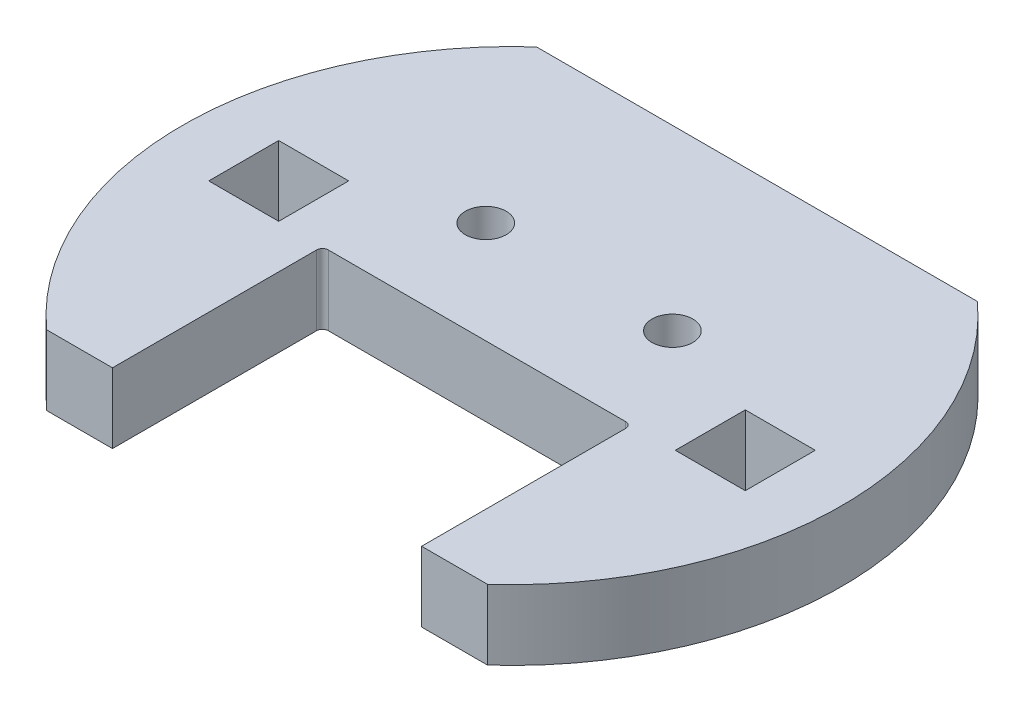
from build123d import *

# Parameters (mm, degrees)
SALIENTE_EXTRUIR1_DEPTH = 6
CROQUIS7_R              = 40
SALIENTE_EXTRUIR5_DEPTH = 6
SALIENTE_EXTRUIR3_DEPTH = 6
CROQUIS6_R              = 1.75
SALIENTE_EXTRUIR4_DEPTH = 6
CROQUIS8_W              = 6
CROQUIS8_H              = 6
CORTAR_EXTRUIR1_DEPTH   = 25
CROQUIS9_W              = 322
CROQUIS9_H              = 247
CORTAR_EXTRUIR2_DEPTH   = 12
CROQUIS10_R             = 28.25
CORTAR_EXTRUIR3_DEPTH   = 6


with BuildPart() as part:
    # Croquis1 → Saliente-Extruir1 (new body)
    with BuildSketch(Plane(origin=(0, 0, 0), x_dir=(1, 0, 0), z_dir=(0, 1, 0))):
        with BuildLine():
            Line((-161, 103.5), (-38.791887254, 9.756509788))
            ThreePointArc((-38.791887254, 9.756509788), (-40, 0), (-38.791887254, -9.756509788))
            Line((-38.791887254, -9.756509788), (-161, -103.5))
            Line((-161, -103.5), (-161, -123.5))
            Line((-161, -123.5), (-141, -123.5))
            Line((-141, -123.5), (-22.823766962, -32.84928708))
            ThreePointArc((-22.823766962, -32.84928708), (0, -40), (22.823766962, -32.84928708))
            Line((22.823766962, -32.84928708), (141, -123.5))
            Line((141, -123.5), (161, -123.5))
            Line((161, -123.5), (161, -103.5))
            Line((161, -103.5), (38.791887254, -9.756509788))
            ThreePointArc((38.791887254, -9.756509788), (40, 0), (38.791887254, 9.756509788))
            Line((38.791887254, 9.756509788), (161, 103.5))
            Line((161, 103.5), (161, 123.5))
            Line((161, 123.5), (141, 123.5))
            Line((141, 123.5), (22.823766962, 32.84928708))
            ThreePointArc((22.823766962, 32.84928708), (0, 40), (-22.823766962, 32.84928708))
            Line((-22.823766962, 32.84928708), (-141, 123.5))
            Line((-141, 123.5), (-161, 123.5))
            Line((-161, 123.5), (-161, 103.5))
        make_face()
    extrude(amount=SALIENTE_EXTRUIR1_DEPTH)

    # Croquis7 → Saliente-Extruir5 (add)
    with BuildSketch(Plane(origin=(0, 0, 0), x_dir=(-1, 0, 0), z_dir=(0, -1, 0))):
        Circle(CROQUIS7_R)
    extrude(amount=SALIENTE_EXTRUIR5_DEPTH)

    # Croquis5 → Saliente-Extruir3 (add)
    with BuildSketch(Plane.XZ.offset(6)):
        with BuildLine():
            Line((18.896097481, -21), (-18.896097481, -21))
            ThreePointArc((-18.896097481, -21), (-28.25, 0), (-18.896097481, 21))
            Line((-18.896097481, 21), (-13.25, 21))
            Line((-13.25, 21), (-13.25, -11))
            Line((-13.25, -11), (13.25, -11))
            Line((13.25, -11), (13.25, 21))
            Line((13.25, 21), (18.896097481, 21))
            ThreePointArc((18.896097481, 21), (28.25, 0), (18.896097481, -21))
        make_face()
    extrude(amount=SALIENTE_EXTRUIR3_DEPTH)

    # Croquis6 → Saliente-Extruir4 (add)
    with BuildSketch(Plane.XZ.offset(12)):
        with BuildLine():
            Line((-18.896097481, 21), (-13.25, 21))
            Line((-13.25, 21), (-13.25, 3.5))
            ThreePointArc((-13.25, 3.5), (-13.103553391, 3.146446609), (-12.75, 3))
            Line((-12.75, 3), (12.75, 3))
            ThreePointArc((12.75, 3), (13.103553391, 3.146446609), (13.25, 3.5))
            Line((13.25, 3.5), (13.25, 21))
            Line((13.25, 21), (18.896097481, 21))
            ThreePointArc((18.896097481, 21), (28.25, 0), (18.896097481, -21))
            Line((18.896097481, -21), (-18.896097481, -21))
            ThreePointArc((-18.896097481, -21), (-28.25, 0), (-18.896097481, 21))
        make_face()
        with Locations((-8, -5.75)):
            Circle(CROQUIS6_R, mode=Mode.SUBTRACT)
        with Locations((8, -5.75)):
            Circle(CROQUIS6_R, mode=Mode.SUBTRACT)
    extrude(amount=SALIENTE_EXTRUIR4_DEPTH)

    # Croquis8 → Cortar-Extruir1 (cut, through all)
    with BuildSketch(Plane.XZ.offset(18)):
        with Locations((-20, 0)):
            Rectangle(CROQUIS8_W, CROQUIS8_H)
        with Locations((20, 0)):
            Rectangle(CROQUIS8_W, CROQUIS8_H)
    extrude(amount=-CORTAR_EXTRUIR1_DEPTH, mode=Mode.SUBTRACT)

    # Croquis9 → Cortar-Extruir2 (cut)
    with BuildSketch(Plane(origin=(0, 6, 0), x_dir=(1, 0, 0), z_dir=(0, 1, 0))):
        Rectangle(CROQUIS9_W, CROQUIS9_H)
    extrude(amount=-CORTAR_EXTRUIR2_DEPTH, mode=Mode.SUBTRACT)

    # Croquis10 → Cortar-Extruir3 (cut)
    with BuildSketch(Plane(origin=(0, -6, 0), x_dir=(1, 0, 0), z_dir=(0, 1, 0))):
        Circle(CROQUIS10_R)
    extrude(amount=-CORTAR_EXTRUIR3_DEPTH, mode=Mode.SUBTRACT)


solid = part.part
